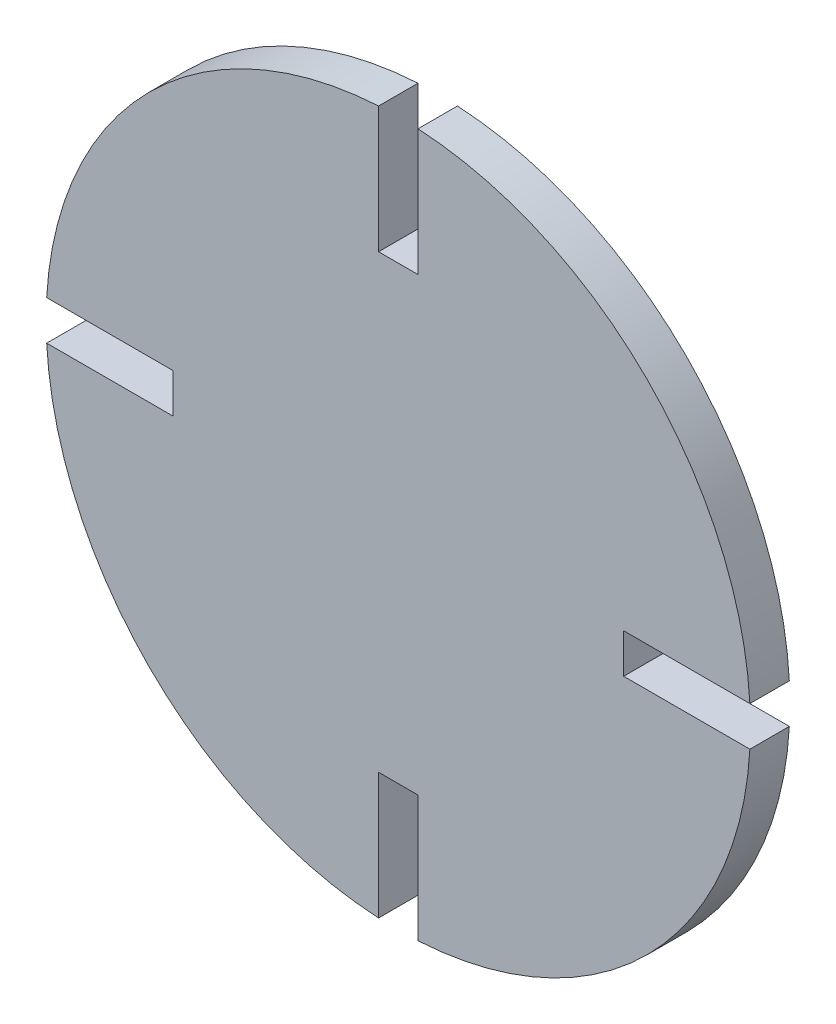
from build123d import *

# Parameters (mm, degrees)
CROQUIS1_R              = 25
SALIENTE_EXTRUIR1_DEPTH = 2.8
CROQUIS2_W              = 2.8
CROQUIS2_H              = 18
CORTAR_EXTRUIR1_DEPTH   = 3.8
MATRIZC1_COUNT          = 4


with BuildPart() as part:
    # Croquis1 → Saliente-Extruir1 (new body)
    with BuildSketch(Plane.XY):
        Circle(CROQUIS1_R)
    extrude(amount=SALIENTE_EXTRUIR1_DEPTH)

    # Croquis2 → Cortar-Extruir1 (cut, through all)
    with BuildSketch(Plane.XY):
        with Locations((0, 25)):
            Rectangle(CROQUIS2_W, CROQUIS2_H)
    cortar_extruir1 = extrude(amount=CORTAR_EXTRUIR1_DEPTH, mode=Mode.SUBTRACT)

    # MatrizC1: Cortar-Extruir1 ×4 about axis
    matrizc1_axis = Axis((0, 0, 0), (0, 0, 1))
    for i in range(1, MATRIZC1_COUNT):
        add(cortar_extruir1.rotate(matrizc1_axis, i * 360 / MATRIZC1_COUNT), mode=Mode.SUBTRACT)


solid = part.part
